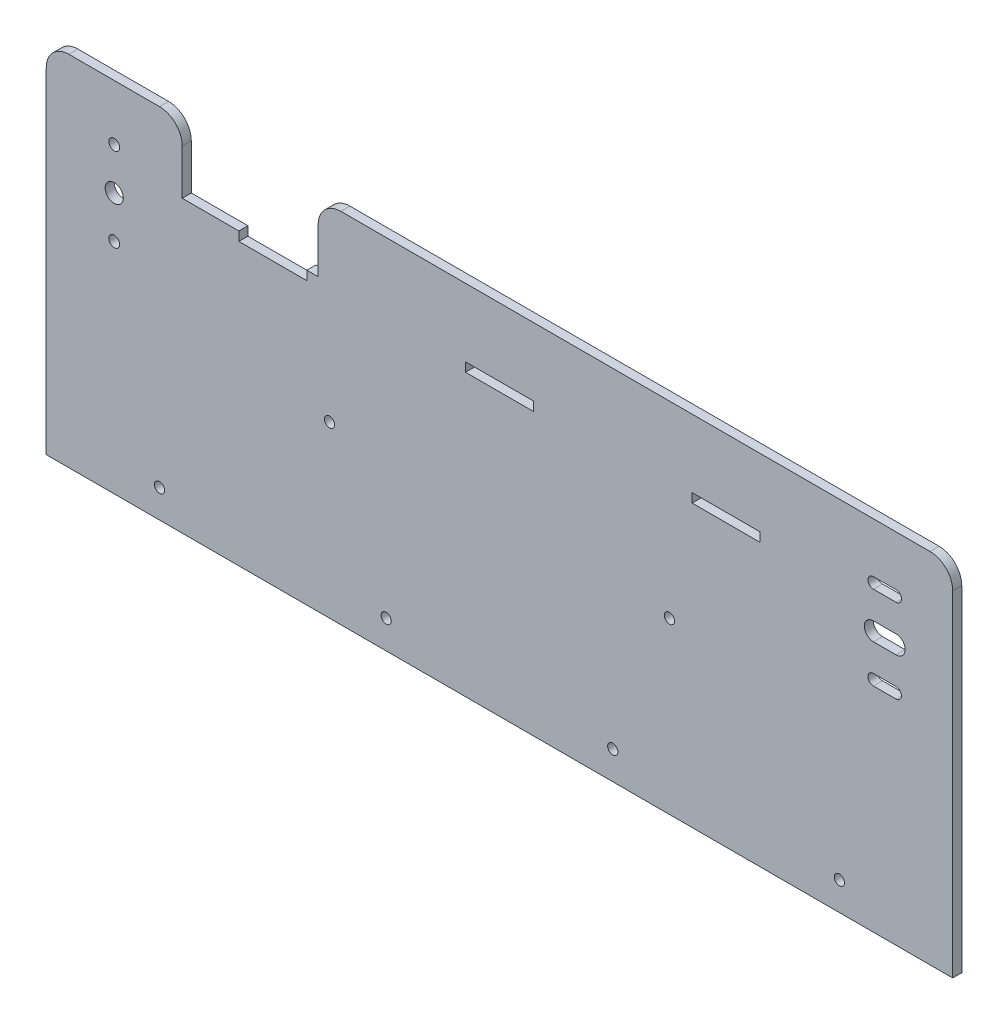
from build123d import *

# Parameters (mm, degrees)
ESBO_O1_R                = 2.4
ESBO_O1_W                = 30
ESBO_O1_H                = 4
RESSALTO_EXTRUS_O1_DEPTH = 4
ESBO_O3_R                = 4
CORTE_EXTRUS_O1_DEPTH    = 6
FURO_COM_FOLGA_DE_M41_D  = 4.5
ESBO_O7_W                = 60
ESBO_O7_H                = 2
CORTE_EXTRUS_O4_DEPTH    = 5
RESSALTO_EXTRUS_O2_DEPTH = 4


with BuildPart() as part:
    # Esboço1 → Ressalto-extrusão1 (new body)
    with BuildSketch(Plane.XY):
        with BuildLine():
            Line((0, 0), (400, 0))
            Line((400, 0), (400, 140))
            ThreePointArc((400, 140), (397.071067812, 147.071067812), (390, 150))
            Line((390, 150), (130, 150))
            ThreePointArc((130, 150), (122.928932188, 147.071067812), (120, 140))
            Line((120, 140), (120, 130))
            Line((120, 130), (60, 130))
            Line((60, 130), (60, 140))
            ThreePointArc((60, 140), (57.071067812, 147.071067812), (50, 150))
            Line((50, 150), (10, 150))
            ThreePointArc((10, 150), (2.928932188, 147.071067812), (0, 140))
            Line((0, 140), (0, 0))
        make_face()
        with Locations((30, 133.5)):
            Circle(ESBO_O1_R, mode=Mode.SUBTRACT)
        with Locations((30, 96.5)):
            Circle(ESBO_O1_R, mode=Mode.SUBTRACT)
        with Locations((100, 126)):
            Rectangle(ESBO_O1_W, ESBO_O1_H, mode=Mode.SUBTRACT)
        with Locations((200, 126)):
            Rectangle(ESBO_O1_W, ESBO_O1_H, mode=Mode.SUBTRACT)
        with Locations((300, 126)):
            Rectangle(ESBO_O1_W, ESBO_O1_H, mode=Mode.SUBTRACT)
        with BuildLine():
            Line((365, 135.9), (375, 135.9))
            ThreePointArc((375, 135.9), (377.4, 133.5), (375, 131.1))
            Line((375, 131.1), (365, 131.1))
            ThreePointArc((365, 131.1), (362.6, 133.5), (365, 135.9))
        make_face(mode=Mode.SUBTRACT)
        with BuildLine():
            Line((365, 98.9), (375, 98.9))
            ThreePointArc((375, 98.9), (377.4, 96.5), (375, 94.1))
            Line((375, 94.1), (365, 94.1))
            ThreePointArc((365, 94.1), (362.6, 96.5), (365, 98.9))
        make_face(mode=Mode.SUBTRACT)
    extrude(amount=RESSALTO_EXTRUS_O1_DEPTH)

    # Esboço3 → Corte-extrusão1 (cut)
    with BuildSketch(Plane.XY.offset(4)):
        with Locations((30, 115)):
            Circle(ESBO_O3_R)
        with BuildLine():
            Line((365, 119), (375, 119))
            ThreePointArc((375, 119), (379, 115), (375, 111))
            Line((375, 111), (365, 111))
            ThreePointArc((365, 111), (361, 115), (365, 119))
        make_face()
    extrude(amount=-CORTE_EXTRUS_O1_DEPTH, mode=Mode.SUBTRACT)

    # Furo com folga de M41 (through all)
    with Locations(Plane(origin=(350, 12.5, 4), x_dir=(1, 0, 0), z_dir=(0, 0, 1))):
        with Locations((0, 0), (-225, 62.5), (-75, 62.5), (-300, 0), (-200, 0), (-100, 0)):
            Hole(FURO_COM_FOLGA_DE_M41_D / 2)

    # Esboço7 → Corte-extrusão4 (cut, through all)
    with BuildSketch(Plane.XY.offset(4)):
        with Locations((90, 129)):
            Rectangle(ESBO_O7_W, ESBO_O7_H)
    extrude(amount=-CORTE_EXTRUS_O4_DEPTH, mode=Mode.SUBTRACT)

    # Esboço8 → Ressalto-extrusão2 (add)
    with BuildSketch(Plane.XY.offset(4)):
        with BuildLine():
            Line((10, 158), (50, 158))
            ThreePointArc((50, 158), (57.071067812, 155.071067812), (60, 148))
            Line((60, 148), (60, 140))
            ThreePointArc((60, 140), (57.071067812, 147.071067812), (50, 150))
            Line((50, 150), (10, 150))
            ThreePointArc((10, 150), (2.928932188, 147.071067812), (0, 140))
            Line((0, 140), (0, 148))
            ThreePointArc((0, 148), (2.928932188, 155.071067812), (10, 158))
        make_face()
        with BuildLine():
            Line((120, 140), (120, 148))
            ThreePointArc((120, 148), (122.928932188, 155.071067812), (130, 158))
            Line((130, 158), (390, 158))
            ThreePointArc((390, 158), (397.071067812, 155.071067812), (400, 148))
            Line((400, 148), (400, 140))
            ThreePointArc((400, 140), (397.071067812, 147.071067812), (390, 150))
            Line((390, 150), (130, 150))
            ThreePointArc((130, 150), (122.928932188, 147.071067812), (120, 140))
        make_face()
    extrude(amount=-RESSALTO_EXTRUS_O2_DEPTH)


solid = part.part
